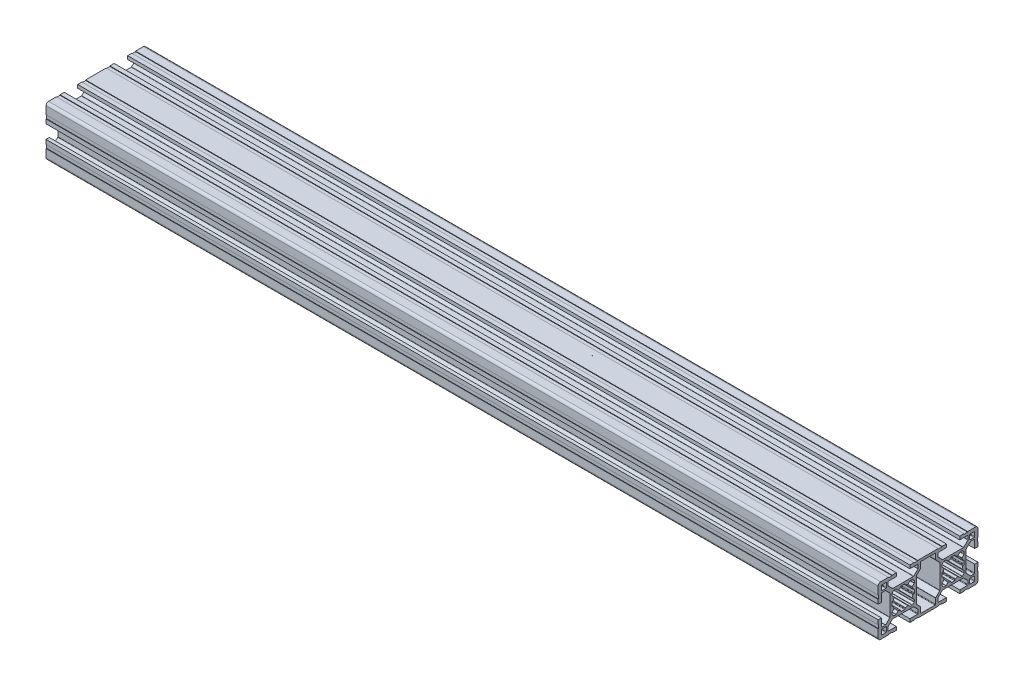
from build123d import *

# Parameters (mm, degrees)
RETANGULAR_PF30_02_PERFIL_3060_B_SICO_DEPTH = 500


with BuildPart() as part:
    # Sketch11 → Retangular PF30-02 - PERFIL 3060 BÁSICO(1) (new body)
    with BuildSketch(Plane.YZ.offset(-250)):
        with BuildLine():
            Line((-10.467761979, 23.914900409), (-7.987862303, 21.435000909))
            ThreePointArc((-7.987862303, 21.435000909), (-7.922830472, 21.337673902), (-7.89999433, 21.222868867))
            Line((-7.89999433, 21.222868867), (-7.89999433, 8.78267257))
            ThreePointArc((-7.89999433, 8.78267257), (-7.922830472, 8.667867535), (-7.987862303, 8.570540528))
            Line((-7.987862303, 8.570540528), (-10.467761979, 6.090641028))
            ThreePointArc((-10.467761979, 6.090641028), (-10.565088981, 6.025609208), (-10.679894006, 6.00277307))
            Line((-10.679894006, 6.00277307), (-12.699995366, 6.00277307))
            ThreePointArc((-12.699995366, 6.00277307), (-12.9121274, 6.090641035), (-12.999995366, 6.30277307))
            Line((-12.999995366, 6.30277307), (-12.999995366, 10.952772018))
            Line((-12.999995366, 10.952772018), (-14.999995923, 10.952772018))
            Line((-14.999995923, 10.952772018), (-14.999995923, 8.402773901))
            Line((-14.999995923, 8.402773901), (-14.699995922, 8.402773901))
            Line((-14.699995922, 8.402773901), (-14.699995922, 6.2027739))
            Line((-14.699995922, 6.2027739), (-14.999995923, 6.2027739))
            Line((-14.999995923, 6.2027739), (-14.999995923, -6.197224309))
            Line((-14.999995923, -6.197224309), (-14.699995922, -6.197224309))
            Line((-14.699995922, -6.197224309), (-14.699995922, -8.397224309))
            Line((-14.699995922, -8.397224309), (-14.999995923, -8.397224309))
            Line((-14.999995923, -8.397224309), (-14.999995923, -10.947222427))
            Line((-14.999995923, -10.947222427), (-12.999995366, -10.947222427))
            Line((-12.999995366, -10.947222427), (-12.999995366, -6.297223478))
            ThreePointArc((-12.999995366, -6.297223478), (-12.9121274, -6.085091444), (-12.699995366, -5.997223478))
            Line((-12.699995366, -5.997223478), (-10.679894006, -5.997223478))
            ThreePointArc((-10.679894006, -5.997223478), (-10.565088981, -6.020059616), (-10.467761979, -6.085091436))
            Line((-10.467761979, -6.085091436), (-7.987862303, -8.564990936))
            ThreePointArc((-7.987862303, -8.564990936), (-7.922830472, -8.662317943), (-7.89999433, -8.777122978))
            Line((-7.89999433, -8.777122978), (-7.89999433, -21.217319276))
            ThreePointArc((-7.89999433, -21.217319276), (-7.922830472, -21.33212431), (-7.987862303, -21.429451318))
            Line((-7.987862303, -21.429451318), (-10.467761979, -23.909350818))
            ThreePointArc((-10.467761979, -23.909350818), (-10.565088981, -23.974382637), (-10.679894006, -23.997218776))
            Line((-10.679894006, -23.997218776), (-12.699995366, -23.997218776))
            ThreePointArc((-12.699995366, -23.997218776), (-12.9121274, -23.90935081), (-12.999995366, -23.697218776))
            Line((-12.999995366, -23.697218776), (-12.999995366, -19.047219827))
            Line((-12.999995366, -19.047219827), (-14.999995923, -19.047219827))
            Line((-14.999995923, -19.047219827), (-14.999995923, -21.597217945))
            Line((-14.999995923, -21.597217945), (-14.699995922, -21.597217945))
            Line((-14.699995922, -21.597217945), (-14.699995922, -23.797217945))
            Line((-14.699995922, -23.797217945), (-14.999995923, -23.797217945))
            Line((-14.999995923, -23.797217945), (-14.999995923, -28.497216952))
            ThreePointArc((-14.999995923, -28.497216952), (-14.560656066, -29.557877193), (-13.499995825, -29.997217049))
            Line((-13.499995825, -29.997217049), (-8.799996802, -29.997217049))
            Line((-8.799996802, -29.997217049), (-8.799996802, -29.697217049))
            Line((-8.799996802, -29.697217049), (-6.599996802, -29.697217049))
            Line((-6.599996802, -29.697217049), (-6.599996802, -29.99721705))
            Line((-6.599996802, -29.99721705), (-4.0499987, -29.99721705))
            Line((-4.0499987, -29.99721705), (-4.0499987, -27.997216493))
            Line((-4.0499987, -27.997216493), (-8.699997649, -27.997216493))
            ThreePointArc((-8.699997649, -27.997216493), (-8.912129683, -27.909348527), (-8.999997649, -27.697216493))
            Line((-8.999997649, -27.697216493), (-8.999997649, -25.677115133))
            ThreePointArc((-8.999997649, -25.677115133), (-8.977161511, -25.562310108), (-8.912129691, -25.464983106))
            Line((-8.912129691, -25.464983106), (-6.432230191, -22.98508343))
            ThreePointArc((-6.432230191, -22.98508343), (-6.334903184, -22.920051599), (-6.220098149, -22.897215457))
            Line((-6.220098149, -22.897215457), (6.220098149, -22.897215457))
            ThreePointArc((6.220098149, -22.897215457), (6.334903184, -22.920051599), (6.432230191, -22.98508343))
            Line((6.432230191, -22.98508343), (8.912129691, -25.464983106))
            ThreePointArc((8.912129691, -25.464983106), (8.977161511, -25.562310108), (8.999997649, -25.677115133))
            Line((8.999997649, -25.677115133), (8.999997649, -27.697216493))
            ThreePointArc((8.999997649, -27.697216493), (8.912129683, -27.909348527), (8.699997649, -27.997216493))
            Line((8.699997649, -27.997216493), (4.0499987, -27.997216493))
            Line((4.0499987, -27.997216493), (4.0499987, -29.99721705))
            Line((4.0499987, -29.99721705), (6.599996802, -29.99721705))
            Line((6.599996802, -29.99721705), (6.599996802, -29.697217049))
            Line((6.599996802, -29.697217049), (8.799996802, -29.697217049))
            Line((8.799996802, -29.697217049), (8.799996802, -29.997217049))
            Line((8.799996802, -29.997217049), (13.499995825, -29.997217049))
            ThreePointArc((13.499995825, -29.997217049), (14.560656066, -29.557877193), (14.999995923, -28.497216952))
            Line((14.999995923, -28.497216952), (14.999995923, -23.797217945))
            Line((14.999995923, -23.797217945), (14.699995922, -23.797217945))
            Line((14.699995922, -23.797217945), (14.699995922, -21.597217945))
            Line((14.699995922, -21.597217945), (14.999995923, -21.597217945))
            Line((14.999995923, -21.597217945), (14.999995923, -19.047219827))
            Line((14.999995923, -19.047219827), (12.999995366, -19.047219827))
            Line((12.999995366, -19.047219827), (12.999995366, -23.697218776))
            ThreePointArc((12.999995366, -23.697218776), (12.9121274, -23.90935081), (12.699995366, -23.997218776))
            Line((12.699995366, -23.997218776), (10.679894006, -23.997218776))
            ThreePointArc((10.679894006, -23.997218776), (10.565088981, -23.974382637), (10.467761979, -23.909350818))
            Line((10.467761979, -23.909350818), (7.987862303, -21.429451318))
            ThreePointArc((7.987862303, -21.429451318), (7.922830472, -21.33212431), (7.89999433, -21.217319276))
            Line((7.89999433, -21.217319276), (7.89999433, -8.777122978))
            ThreePointArc((7.89999433, -8.777122978), (7.922830472, -8.662317943), (7.987862303, -8.564990936))
            Line((7.987862303, -8.564990936), (10.467761979, -6.085091436))
            ThreePointArc((10.467761979, -6.085091436), (10.565088981, -6.020059616), (10.679894006, -5.997223478))
            Line((10.679894006, -5.997223478), (12.699995366, -5.997223478))
            ThreePointArc((12.699995366, -5.997223478), (12.9121274, -6.085091444), (12.999995366, -6.297223478))
            Line((12.999995366, -6.297223478), (12.999995366, -10.947222427))
            Line((12.999995366, -10.947222427), (14.999995923, -10.947222427))
            Line((14.999995923, -10.947222427), (14.999995923, -8.397224309))
            Line((14.999995923, -8.397224309), (14.699995922, -8.397224309))
            Line((14.699995922, -8.397224309), (14.699995922, -6.197224309))
            Line((14.699995922, -6.197224309), (14.999995923, -6.197224309))
            Line((14.999995923, -6.197224309), (14.999995923, 6.2027739))
            Line((14.999995923, 6.2027739), (14.699995922, 6.2027739))
            Line((14.699995922, 6.2027739), (14.699995922, 8.402773901))
            Line((14.699995922, 8.402773901), (14.999995923, 8.402773901))
            Line((14.999995923, 8.402773901), (14.999995923, 10.952772018))
            Line((14.999995923, 10.952772018), (12.999995366, 10.952772018))
            Line((12.999995366, 10.952772018), (12.999995366, 6.30277307))
            ThreePointArc((12.999995366, 6.30277307), (12.9121274, 6.090641035), (12.699995366, 6.00277307))
            Line((12.699995366, 6.00277307), (10.679894006, 6.00277307))
            ThreePointArc((10.679894006, 6.00277307), (10.565088981, 6.025609208), (10.467761979, 6.090641028))
            Line((10.467761979, 6.090641028), (7.987862303, 8.570540528))
            ThreePointArc((7.987862303, 8.570540528), (7.922830472, 8.667867535), (7.89999433, 8.78267257))
            Line((7.89999433, 8.78267257), (7.89999433, 21.222868867))
            ThreePointArc((7.89999433, 21.222868867), (7.922830472, 21.337673902), (7.987862303, 21.435000909))
            Line((7.987862303, 21.435000909), (10.467761979, 23.914900409))
            ThreePointArc((10.467761979, 23.914900409), (10.565088981, 23.979932229), (10.679894006, 24.002768367))
            Line((10.679894006, 24.002768367), (12.699995366, 24.002768367))
            ThreePointArc((12.699995366, 24.002768367), (12.9121274, 23.914900401), (12.999995366, 23.702768367))
            Line((12.999995366, 23.702768367), (12.999995366, 19.052769418))
            Line((12.999995366, 19.052769418), (14.999995923, 19.052769418))
            Line((14.999995923, 19.052769418), (14.999995923, 21.602767536))
            Line((14.999995923, 21.602767536), (14.699995922, 21.602767536))
            Line((14.699995922, 21.602767536), (14.699995922, 23.802767536))
            Line((14.699995922, 23.802767536), (14.999995923, 23.802767536))
            Line((14.999995923, 23.802767536), (14.999995923, 28.502766544))
            ThreePointArc((14.999995923, 28.502766544), (14.560656066, 29.563426784), (13.499995825, 30.002766641))
            Line((13.499995825, 30.002766641), (8.799996802, 30.002766641))
            Line((8.799996802, 30.002766641), (8.799996802, 29.702766641))
            Line((8.799996802, 29.702766641), (6.599996802, 29.702766641))
            Line((6.599996802, 29.702766641), (6.599996802, 30.002766641))
            Line((6.599996802, 30.002766641), (4.0499987, 30.002766641))
            Line((4.0499987, 30.002766641), (4.0499987, 28.002766084))
            Line((4.0499987, 28.002766084), (8.699997649, 28.002766084))
            ThreePointArc((8.699997649, 28.002766084), (8.912129683, 27.914898119), (8.999997649, 27.702766084))
            Line((8.999997649, 27.702766084), (8.999997649, 25.682664725))
            ThreePointArc((8.999997649, 25.682664725), (8.977161511, 25.5678597), (8.912129691, 25.470532698))
            Line((8.912129691, 25.470532698), (6.432230191, 22.990633021))
            ThreePointArc((6.432230191, 22.990633021), (6.334903184, 22.92560119), (6.220098149, 22.902765048))
            Line((6.220098149, 22.902765048), (-6.220098149, 22.902765048))
            ThreePointArc((-6.220098149, 22.902765048), (-6.334903184, 22.92560119), (-6.432230191, 22.990633021))
            Line((-6.432230191, 22.990633021), (-8.912129691, 25.470532698))
            ThreePointArc((-8.912129691, 25.470532698), (-8.977161511, 25.5678597), (-8.999997649, 25.682664725))
            Line((-8.999997649, 25.682664725), (-8.999997649, 27.702766084))
            ThreePointArc((-8.999997649, 27.702766084), (-8.912129683, 27.914898119), (-8.699997649, 28.002766084))
            Line((-8.699997649, 28.002766084), (-4.0499987, 28.002766084))
            Line((-4.0499987, 28.002766084), (-4.0499987, 30.002766641))
            Line((-4.0499987, 30.002766641), (-6.599996802, 30.002766641))
            Line((-6.599996802, 30.002766641), (-6.599996802, 29.702766641))
            Line((-6.599996802, 29.702766641), (-8.799996802, 29.702766641))
            Line((-8.799996802, 29.702766641), (-8.799996802, 30.002766641))
            Line((-8.799996802, 30.002766641), (-13.499995825, 30.002766641))
            ThreePointArc((-13.499995825, 30.002766641), (-14.560656066, 29.563426784), (-14.999995923, 28.502766544))
            Line((-14.999995923, 28.502766544), (-14.999995923, 23.802767536))
            Line((-14.999995923, 23.802767536), (-14.699995922, 23.802767536))
            Line((-14.699995922, 23.802767536), (-14.699995922, 21.602767536))
            Line((-14.699995922, 21.602767536), (-14.999995923, 21.602767536))
            Line((-14.999995923, 21.602767536), (-14.999995923, 19.052769418))
            Line((-14.999995923, 19.052769418), (-12.999995366, 19.052769418))
            Line((-12.999995366, 19.052769418), (-12.999995366, 23.702768367))
            ThreePointArc((-12.999995366, 23.702768367), (-12.9121274, 23.914900401), (-12.699995366, 24.002768367))
            Line((-12.699995366, 24.002768367), (-10.679894006, 24.002768367))
            ThreePointArc((-10.679894006, 24.002768367), (-10.565088981, 23.979932229), (-10.467761979, 23.914900409))
        make_face()
        with BuildLine():
            Line((-9.846446918, -4.590642769), (-7.422182, -7.014907859))
            ThreePointArc((-7.422182, -7.014907859), (-7.324854993, -7.07993969), (-7.210049959, -7.102775832))
            Line((-7.210049959, -7.102775832), (7.210049959, -7.102775832))
            ThreePointArc((7.210049959, -7.102775832), (7.324854993, -7.07993969), (7.422182, -7.014907859))
            Line((7.422182, -7.014907859), (9.846446918, -4.590642769))
            ThreePointArc((9.846446918, -4.590642769), (9.943773925, -4.525610938), (10.05857896, -4.502774796))
            Line((10.05857896, -4.502774796), (13.2, -4.502774796))
            ThreePointArc((13.2, -4.502774796), (13.412132034, -4.41490683), (13.5, -4.202774796))
            Line((13.5, -4.202774796), (13.5, 4.197225204))
            ThreePointArc((13.5, 4.197225204), (13.412132034, 4.409357239), (13.2, 4.497225204))
            Line((13.2, 4.497225204), (10.05857896, 4.497225204))
            ThreePointArc((10.05857896, 4.497225204), (9.943773925, 4.520061347), (9.846446918, 4.585093178))
            Line((9.846446918, 4.585093178), (7.422182001, 7.009358267))
            ThreePointArc((7.422182001, 7.009358267), (7.324854993, 7.074390098), (7.210049959, 7.097226241))
            Line((7.210049959, 7.097226241), (-7.210049958, 7.097226241))
            ThreePointArc((-7.210049958, 7.097226241), (-7.324854993, 7.074390098), (-7.422182, 7.009358267))
            Line((-7.422182, 7.009358267), (-9.846446917, 4.585093178))
            ThreePointArc((-9.846446917, 4.585093178), (-9.943773925, 4.520061347), (-10.058578959, 4.497225204))
            Line((-10.058578959, 4.497225204), (-13.2, 4.497225204))
            ThreePointArc((-13.2, 4.497225204), (-13.412132034, 4.409357239), (-13.5, 4.197225204))
            Line((-13.5, 4.197225204), (-13.5, -4.202774796))
            ThreePointArc((-13.5, -4.202774796), (-13.412132034, -4.41490683), (-13.2, -4.502774796))
            Line((-13.2, -4.502774796), (-10.05857896, -4.502774796))
            ThreePointArc((-10.05857896, -4.502774796), (-9.943773925, -4.525610938), (-9.846446918, -4.590642769))
        make_face(mode=Mode.SUBTRACT)
        with BuildLine():
            Line((-6.69999433, 15.952769357), (-6.69999433, 14.05277208))
            ThreePointArc((-6.69999433, 14.05277208), (-6.612125883, 13.840639564), (-6.399992969, 13.75277208))
            Line((-6.399992969, 13.75277208), (-6.157923707, 13.752773178))
            ThreePointArc((-6.157923707, 13.752773178), (-5.973489249, 13.689383475), (-5.866996881, 13.526001408))
            ThreePointArc((-5.866996881, 13.526001408), (-5.679815238, 12.918976375), (-5.430017698, 12.334923683))
            ThreePointArc((-5.430017698, 12.334923683), (-5.403317864, 12.15354701), (-5.487142739, 11.990501713))
            Line((-5.487142739, 11.990501713), (-6.612126364, 10.865518089))
            ThreePointArc((-6.612126364, 10.865518089), (-6.677158189, 10.768191084), (-6.69999433, 10.653386054))
            Line((-6.69999433, 10.653386054), (-6.69999433, 9.563210784))
            ThreePointArc((-6.69999433, 9.563210784), (-6.677158176, 9.448405723), (-6.612126315, 9.351078701))
            Line((-6.612126315, 9.351078701), (-6.131909052, 8.870861658))
            Line((-6.131909052, 8.870861658), (-5.651692017, 8.390644403))
            ThreePointArc((-5.651692017, 8.390644403), (-5.554364996, 8.325612542), (-5.439559934, 8.302776389))
            Line((-5.439559934, 8.302776389), (-4.349384664, 8.302776389))
            ThreePointArc((-4.349384664, 8.302776389), (-4.234579634, 8.325612529), (-4.13725263, 8.390644354))
            Line((-4.13725263, 8.390644354), (-3.012269005, 9.515627979))
            ThreePointArc((-3.012269005, 9.515627979), (-2.849223708, 9.599452854), (-2.667847035, 9.572753021))
            ThreePointArc((-2.667847035, 9.572753021), (-2.083794343, 9.322955481), (-1.476769311, 9.135773837))
            ThreePointArc((-1.476769311, 9.135773837), (-1.313387244, 9.02928147), (-1.249997541, 8.844847011))
            Line((-1.249997541, 8.844847011), (-1.249998639, 8.60277775))
            ThreePointArc((-1.249998639, 8.60277775), (-1.162131155, 8.390644836), (-0.949998639, 8.302776389))
            Line((-0.949998639, 8.302776389), (0.949998639, 8.302776389))
            ThreePointArc((0.949998639, 8.302776389), (1.162131155, 8.390644836), (1.249998639, 8.60277775))
            Line((1.249998639, 8.60277775), (1.249997541, 8.844847011))
            ThreePointArc((1.249997541, 8.844847011), (1.313387244, 9.02928147), (1.476769311, 9.135773837))
            ThreePointArc((1.476769311, 9.135773837), (2.083794343, 9.322955481), (2.667847035, 9.572753021))
            ThreePointArc((2.667847035, 9.572753021), (2.849223708, 9.599452854), (3.012269005, 9.515627979))
            Line((3.012269005, 9.515627979), (4.13725263, 8.390644354))
            ThreePointArc((4.13725263, 8.390644354), (4.234579634, 8.325612529), (4.349384664, 8.302776389))
            Line((4.349384664, 8.302776389), (5.439559934, 8.302776389))
            ThreePointArc((5.439559934, 8.302776389), (5.554364996, 8.325612542), (5.651692017, 8.390644403))
            Line((5.651692017, 8.390644403), (6.131909052, 8.870861658))
            Line((6.131909052, 8.870861658), (6.612126315, 9.351078701))
            ThreePointArc((6.612126315, 9.351078701), (6.677158176, 9.448405723), (6.69999433, 9.563210784))
            Line((6.69999433, 9.563210784), (6.69999433, 10.653386054))
            ThreePointArc((6.69999433, 10.653386054), (6.677158189, 10.768191084), (6.612126364, 10.865518089))
            Line((6.612126364, 10.865518089), (5.487142739, 11.990501713))
            ThreePointArc((5.487142739, 11.990501713), (5.403317864, 12.15354701), (5.430017698, 12.334923683))
            ThreePointArc((5.430017698, 12.334923683), (5.679815238, 12.918976375), (5.866996881, 13.526001408))
            ThreePointArc((5.866996881, 13.526001408), (5.973489249, 13.689383475), (6.157923707, 13.752773178))
            Line((6.157923707, 13.752773178), (6.399992969, 13.75277208))
            ThreePointArc((6.399992969, 13.75277208), (6.612125883, 13.840639564), (6.69999433, 14.05277208))
            Line((6.69999433, 14.05277208), (6.69999433, 15.952769357))
            ThreePointArc((6.69999433, 15.952769357), (6.612125883, 16.164901872), (6.399992969, 16.252769357))
            Line((6.399992969, 16.252769357), (6.157923707, 16.252768259))
            ThreePointArc((6.157923707, 16.252768259), (5.973489249, 16.316157962), (5.866996881, 16.479540029))
            ThreePointArc((5.866996881, 16.479540029), (5.679815238, 17.086565061), (5.430017698, 17.670617753))
            ThreePointArc((5.430017698, 17.670617753), (5.403317864, 17.851994426), (5.487142739, 18.015039723))
            Line((5.487142739, 18.015039723), (6.612126364, 19.140023348))
            ThreePointArc((6.612126364, 19.140023348), (6.677158189, 19.237350353), (6.69999433, 19.352155382))
            Line((6.69999433, 19.352155382), (6.69999433, 20.442330653))
            ThreePointArc((6.69999433, 20.442330653), (6.677158176, 20.557135714), (6.612126315, 20.654462736))
            Line((6.612126315, 20.654462736), (6.131909052, 21.134679779))
            Line((6.131909052, 21.134679779), (5.651692017, 21.614897034))
            ThreePointArc((5.651692017, 21.614897034), (5.554364996, 21.679928895), (5.439559934, 21.702765048))
            Line((5.439559934, 21.702765048), (4.349384664, 21.702765048))
            ThreePointArc((4.349384664, 21.702765048), (4.234579634, 21.679928908), (4.13725263, 21.614897082))
            Line((4.13725263, 21.614897082), (3.012269005, 20.489913458))
            ThreePointArc((3.012269005, 20.489913458), (2.849223708, 20.406088583), (2.667847035, 20.432788416))
            ThreePointArc((2.667847035, 20.432788416), (2.083794343, 20.682585956), (1.476769311, 20.869767599))
            ThreePointArc((1.476769311, 20.869767599), (1.313387244, 20.976259967), (1.249997541, 21.160694426))
            Line((1.249997541, 21.160694426), (1.249998639, 21.402763687))
            ThreePointArc((1.249998639, 21.402763687), (1.162131155, 21.614896601), (0.949998639, 21.702765048))
            Line((0.949998639, 21.702765048), (-0.949998639, 21.702765048))
            ThreePointArc((-0.949998639, 21.702765048), (-1.162131155, 21.614896601), (-1.249998639, 21.402763687))
            Line((-1.249998639, 21.402763687), (-1.249997541, 21.160694426))
            ThreePointArc((-1.249997541, 21.160694426), (-1.313387244, 20.976259967), (-1.476769311, 20.869767599))
            ThreePointArc((-1.476769311, 20.869767599), (-2.083794343, 20.682585956), (-2.667847035, 20.432788416))
            ThreePointArc((-2.667847035, 20.432788416), (-2.849223708, 20.406088583), (-3.012269005, 20.489913458))
            Line((-3.012269005, 20.489913458), (-4.13725263, 21.614897082))
            ThreePointArc((-4.13725263, 21.614897082), (-4.234579634, 21.679928908), (-4.349384664, 21.702765048))
            Line((-4.349384664, 21.702765048), (-5.439559934, 21.702765048))
            ThreePointArc((-5.439559934, 21.702765048), (-5.554364996, 21.679928895), (-5.651692017, 21.614897034))
            Line((-5.651692017, 21.614897034), (-6.131909052, 21.134679779))
            Line((-6.131909052, 21.134679779), (-6.612126315, 20.654462736))
            ThreePointArc((-6.612126315, 20.654462736), (-6.677158176, 20.557135714), (-6.69999433, 20.442330653))
            Line((-6.69999433, 20.442330653), (-6.69999433, 19.352155382))
            ThreePointArc((-6.69999433, 19.352155382), (-6.677158189, 19.237350353), (-6.612126364, 19.140023348))
            Line((-6.612126364, 19.140023348), (-5.487142739, 18.015039723))
            ThreePointArc((-5.487142739, 18.015039723), (-5.403317864, 17.851994426), (-5.430017698, 17.670617753))
            ThreePointArc((-5.430017698, 17.670617753), (-5.679815238, 17.086565061), (-5.866996881, 16.479540029))
            ThreePointArc((-5.866996881, 16.479540029), (-5.973489249, 16.316157962), (-6.157923707, 16.252768259))
            Line((-6.157923707, 16.252768259), (-6.399992969, 16.252769357))
            ThreePointArc((-6.399992969, 16.252769357), (-6.612125883, 16.164901872), (-6.69999433, 15.952769357))
        make_face(mode=Mode.SUBTRACT)
        with BuildLine():
            Line((-12.999997649, 25.302766084), (-12.999997649, 27.702766084))
            ThreePointArc((-12.999997649, 27.702766084), (-12.912129683, 27.914898119), (-12.699997649, 28.002766084))
            Line((-12.699997649, 28.002766084), (-10.299997649, 28.002766084))
            ThreePointArc((-10.299997649, 28.002766084), (-10.087865615, 27.914898119), (-9.999997649, 27.702766084))
            Line((-9.999997649, 27.702766084), (-9.999997649, 25.302766084))
            ThreePointArc((-9.999997649, 25.302766084), (-10.087865615, 25.09063405), (-10.299997649, 25.002766084))
            Line((-10.299997649, 25.002766084), (-12.699997649, 25.002766084))
            ThreePointArc((-12.699997649, 25.002766084), (-12.912129683, 25.09063405), (-12.999997649, 25.302766084))
        make_face(mode=Mode.SUBTRACT)
        with BuildLine():
            Line((10.299997649, 25.002766084), (12.699997649, 25.002766084))
            ThreePointArc((12.699997649, 25.002766084), (12.912129683, 25.09063405), (12.999997649, 25.302766084))
            Line((12.999997649, 25.302766084), (12.999997649, 27.702766084))
            ThreePointArc((12.999997649, 27.702766084), (12.912129683, 27.914898119), (12.699997649, 28.002766084))
            Line((12.699997649, 28.002766084), (10.299997649, 28.002766084))
            ThreePointArc((10.299997649, 28.002766084), (10.087865615, 27.914898119), (9.999997649, 27.702766084))
            Line((9.999997649, 27.702766084), (9.999997649, 25.302766084))
            ThreePointArc((9.999997649, 25.302766084), (10.087865615, 25.09063405), (10.299997649, 25.002766084))
        make_face(mode=Mode.SUBTRACT)
        with BuildLine():
            Line((-6.157923707, -13.747223586), (-6.399992969, -13.747222488))
            ThreePointArc((-6.399992969, -13.747222488), (-6.612125883, -13.835089973), (-6.69999433, -14.047222488))
            Line((-6.69999433, -14.047222488), (-6.69999433, -15.947219765))
            ThreePointArc((-6.69999433, -15.947219765), (-6.612125883, -16.159352281), (-6.399992969, -16.247219765))
            Line((-6.399992969, -16.247219765), (-6.157923707, -16.247218667))
            ThreePointArc((-6.157923707, -16.247218667), (-5.973489249, -16.310608371), (-5.866996881, -16.473990437))
            ThreePointArc((-5.866996881, -16.473990437), (-5.679815238, -17.08101547), (-5.430017698, -17.665068162))
            ThreePointArc((-5.430017698, -17.665068162), (-5.403317864, -17.846444835), (-5.487142739, -18.009490132))
            Line((-5.487142739, -18.009490132), (-6.612126364, -19.134473757))
            ThreePointArc((-6.612126364, -19.134473757), (-6.677158189, -19.231800761), (-6.69999433, -19.346605791))
            Line((-6.69999433, -19.346605791), (-6.69999433, -20.436781061))
            ThreePointArc((-6.69999433, -20.436781061), (-6.677158176, -20.551586123), (-6.612126315, -20.648913144))
            Line((-6.612126315, -20.648913144), (-6.131909052, -21.129130187))
            Line((-6.131909052, -21.129130187), (-5.651692017, -21.609347442))
            ThreePointArc((-5.651692017, -21.609347442), (-5.554364996, -21.674379303), (-5.439559934, -21.697215457))
            Line((-5.439559934, -21.697215457), (-4.349384664, -21.697215457))
            ThreePointArc((-4.349384664, -21.697215457), (-4.234579634, -21.674379316), (-4.13725263, -21.609347491))
            Line((-4.13725263, -21.609347491), (-3.012269005, -20.484363866))
            ThreePointArc((-3.012269005, -20.484363866), (-2.849223708, -20.400538991), (-2.667847035, -20.427238825))
            ThreePointArc((-2.667847035, -20.427238825), (-2.083794343, -20.677036365), (-1.476769311, -20.864218008))
            ThreePointArc((-1.476769311, -20.864218008), (-1.313387244, -20.970710376), (-1.249997541, -21.155144834))
            Line((-1.249997541, -21.155144834), (-1.249998639, -21.397214096))
            ThreePointArc((-1.249998639, -21.397214096), (-1.162131155, -21.60934701), (-0.949998639, -21.697215457))
            Line((-0.949998639, -21.697215457), (0.949998639, -21.697215457))
            ThreePointArc((0.949998639, -21.697215457), (1.162131155, -21.60934701), (1.249998639, -21.397214096))
            Line((1.249998639, -21.397214096), (1.249997541, -21.155144834))
            ThreePointArc((1.249997541, -21.155144834), (1.313387244, -20.970710376), (1.476769311, -20.864218008))
            ThreePointArc((1.476769311, -20.864218008), (2.083794343, -20.677036365), (2.667847035, -20.427238825))
            ThreePointArc((2.667847035, -20.427238825), (2.849223708, -20.400538991), (3.012269005, -20.484363866))
            Line((3.012269005, -20.484363866), (4.13725263, -21.609347491))
            ThreePointArc((4.13725263, -21.609347491), (4.234579634, -21.674379316), (4.349384664, -21.697215457))
            Line((4.349384664, -21.697215457), (5.439559934, -21.697215457))
            ThreePointArc((5.439559934, -21.697215457), (5.554364996, -21.674379303), (5.651692017, -21.609347442))
            Line((5.651692017, -21.609347442), (6.131909052, -21.129130187))
            Line((6.131909052, -21.129130187), (6.612126315, -20.648913144))
            ThreePointArc((6.612126315, -20.648913144), (6.677158176, -20.551586123), (6.69999433, -20.436781061))
            Line((6.69999433, -20.436781061), (6.69999433, -19.346605791))
            ThreePointArc((6.69999433, -19.346605791), (6.677158189, -19.231800761), (6.612126364, -19.134473757))
            Line((6.612126364, -19.134473757), (5.487142739, -18.009490132))
            ThreePointArc((5.487142739, -18.009490132), (5.403317864, -17.846444835), (5.430017698, -17.665068162))
            ThreePointArc((5.430017698, -17.665068162), (5.679815238, -17.08101547), (5.866996881, -16.473990437))
            ThreePointArc((5.866996881, -16.473990437), (5.973489249, -16.310608371), (6.157923707, -16.247218667))
            Line((6.157923707, -16.247218667), (6.399992969, -16.247219765))
            ThreePointArc((6.399992969, -16.247219765), (6.612125883, -16.159352281), (6.69999433, -15.947219765))
            Line((6.69999433, -15.947219765), (6.69999433, -14.047222488))
            ThreePointArc((6.69999433, -14.047222488), (6.612125883, -13.835089973), (6.399992969, -13.747222488))
            Line((6.399992969, -13.747222488), (6.157923707, -13.747223586))
            ThreePointArc((6.157923707, -13.747223586), (5.973489249, -13.683833883), (5.866996881, -13.520451817))
            ThreePointArc((5.866996881, -13.520451817), (5.679815238, -12.913426784), (5.430017698, -12.329374092))
            ThreePointArc((5.430017698, -12.329374092), (5.403317864, -12.147997419), (5.487142739, -11.984952122))
            Line((5.487142739, -11.984952122), (6.612126364, -10.859968497))
            ThreePointArc((6.612126364, -10.859968497), (6.677158189, -10.762641493), (6.69999433, -10.647836463))
            Line((6.69999433, -10.647836463), (6.69999433, -9.557661193))
            ThreePointArc((6.69999433, -9.557661193), (6.677158176, -9.442856131), (6.612126315, -9.34552911))
            Line((6.612126315, -9.34552911), (6.131909052, -8.865312067))
            Line((6.131909052, -8.865312067), (5.651692017, -8.385094811))
            ThreePointArc((5.651692017, -8.385094811), (5.554364996, -8.320062951), (5.439559934, -8.297226797))
            Line((5.439559934, -8.297226797), (4.349384664, -8.297226797))
            ThreePointArc((4.349384664, -8.297226797), (4.234579634, -8.320062937), (4.13725263, -8.385094763))
            Line((4.13725263, -8.385094763), (3.012269005, -9.510078388))
            ThreePointArc((3.012269005, -9.510078388), (2.849223708, -9.593903263), (2.667847035, -9.567203429))
            ThreePointArc((2.667847035, -9.567203429), (2.083794343, -9.317405889), (1.476769311, -9.130224246))
            ThreePointArc((1.476769311, -9.130224246), (1.313387244, -9.023731878), (1.249997541, -8.83929742))
            Line((1.249997541, -8.83929742), (1.249998639, -8.597228158))
            ThreePointArc((1.249998639, -8.597228158), (1.162131155, -8.385095244), (0.949998639, -8.297226797))
            Line((0.949998639, -8.297226797), (-0.949998639, -8.297226797))
            ThreePointArc((-0.949998639, -8.297226797), (-1.162131155, -8.385095244), (-1.249998639, -8.597228158))
            Line((-1.249998639, -8.597228158), (-1.249997541, -8.83929742))
            ThreePointArc((-1.249997541, -8.83929742), (-1.313387244, -9.023731878), (-1.476769311, -9.130224246))
            ThreePointArc((-1.476769311, -9.130224246), (-2.083794343, -9.317405889), (-2.667847035, -9.567203429))
            ThreePointArc((-2.667847035, -9.567203429), (-2.849223708, -9.593903263), (-3.012269005, -9.510078388))
            Line((-3.012269005, -9.510078388), (-4.13725263, -8.385094763))
            ThreePointArc((-4.13725263, -8.385094763), (-4.234579634, -8.320062937), (-4.349384664, -8.297226797))
            Line((-4.349384664, -8.297226797), (-5.439559934, -8.297226797))
            ThreePointArc((-5.439559934, -8.297226797), (-5.554364996, -8.320062951), (-5.651692017, -8.385094811))
            Line((-5.651692017, -8.385094811), (-6.131909052, -8.865312067))
            Line((-6.131909052, -8.865312067), (-6.612126315, -9.34552911))
            ThreePointArc((-6.612126315, -9.34552911), (-6.677158176, -9.442856131), (-6.69999433, -9.557661193))
            Line((-6.69999433, -9.557661193), (-6.69999433, -10.647836463))
            ThreePointArc((-6.69999433, -10.647836463), (-6.677158189, -10.762641493), (-6.612126364, -10.859968497))
            Line((-6.612126364, -10.859968497), (-5.487142739, -11.984952122))
            ThreePointArc((-5.487142739, -11.984952122), (-5.403317864, -12.147997419), (-5.430017698, -12.329374092))
            ThreePointArc((-5.430017698, -12.329374092), (-5.679815238, -12.913426784), (-5.866996881, -13.520451817))
            ThreePointArc((-5.866996881, -13.520451817), (-5.973489249, -13.683833883), (-6.157923707, -13.747223586))
        make_face(mode=Mode.SUBTRACT)
        with BuildLine():
            Line((-10.299997649, -24.997216493), (-12.699997649, -24.997216493))
            ThreePointArc((-12.699997649, -24.997216493), (-12.912129683, -25.085084458), (-12.999997649, -25.297216493))
            Line((-12.999997649, -25.297216493), (-12.999997649, -27.697216493))
            ThreePointArc((-12.999997649, -27.697216493), (-12.912129683, -27.909348527), (-12.699997649, -27.997216493))
            Line((-12.699997649, -27.997216493), (-10.299997649, -27.997216493))
            ThreePointArc((-10.299997649, -27.997216493), (-10.087865615, -27.909348527), (-9.999997649, -27.697216493))
            Line((-9.999997649, -27.697216493), (-9.999997649, -25.297216493))
            ThreePointArc((-9.999997649, -25.297216493), (-10.087865615, -25.085084458), (-10.299997649, -24.997216493))
        make_face(mode=Mode.SUBTRACT)
        with BuildLine():
            Line((12.999997649, -25.297216493), (12.999997649, -27.697216493))
            ThreePointArc((12.999997649, -27.697216493), (12.912129683, -27.909348527), (12.699997649, -27.997216493))
            Line((12.699997649, -27.997216493), (10.299997649, -27.997216493))
            ThreePointArc((10.299997649, -27.997216493), (10.087865615, -27.909348527), (9.999997649, -27.697216493))
            Line((9.999997649, -27.697216493), (9.999997649, -25.297216493))
            ThreePointArc((9.999997649, -25.297216493), (10.087865615, -25.085084458), (10.299997649, -24.997216493))
            Line((10.299997649, -24.997216493), (12.699997649, -24.997216493))
            ThreePointArc((12.699997649, -24.997216493), (12.912129683, -25.085084458), (12.999997649, -25.297216493))
        make_face(mode=Mode.SUBTRACT)
    extrude(amount=RETANGULAR_PF30_02_PERFIL_3060_B_SICO_DEPTH)


solid = part.part
